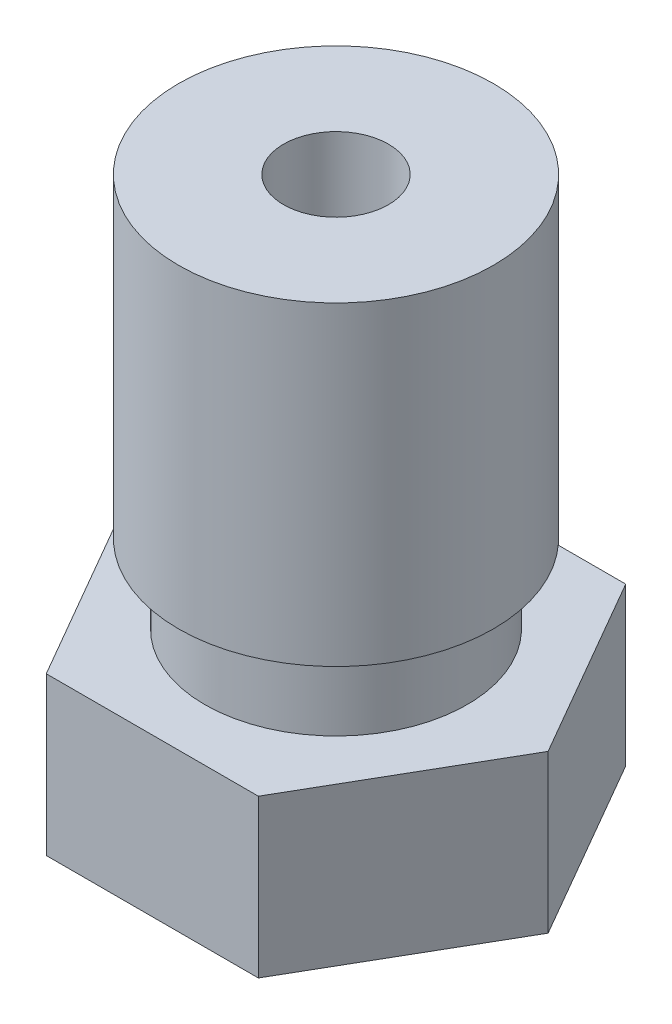
from build123d import *

# Parameters (mm, degrees)
SKETCH1_R           = 1
BOSS_EXTRUDE1_DEPTH = 3


with BuildPart() as part:
    # Sketch1 → Boss-Extrude1 (new body)
    with BuildSketch(Plane(origin=(0, 0, 0), x_dir=(1, 0, 0), z_dir=(0, 1, 0))):
        Polygon((2.020725942, 3.5), (-2.020725942, 3.5), (-4.041451884, 0), (-2.020725942, -3.5), (2.020725942, -3.5), (4.041451884, 0), align=None)
        Circle(SKETCH1_R, mode=Mode.SUBTRACT)
    extrude(amount=BOSS_EXTRUDE1_DEPTH)

    # Sketch2 → Revolve1 (revolve)
    with BuildSketch(Plane.XY):
        Polygon((2.5, 3), (1, 3), (1, 10.5), (3, 10.5), (3, 4.5), (2.5, 4.5), align=None)
        Polygon((1, 0), (1.900415076, 0), (0.5, -2), (0.2, -2), align=None)
    revolve(axis=Axis((0, -2, 0), (0, 1, 0)))


solid = part.part
